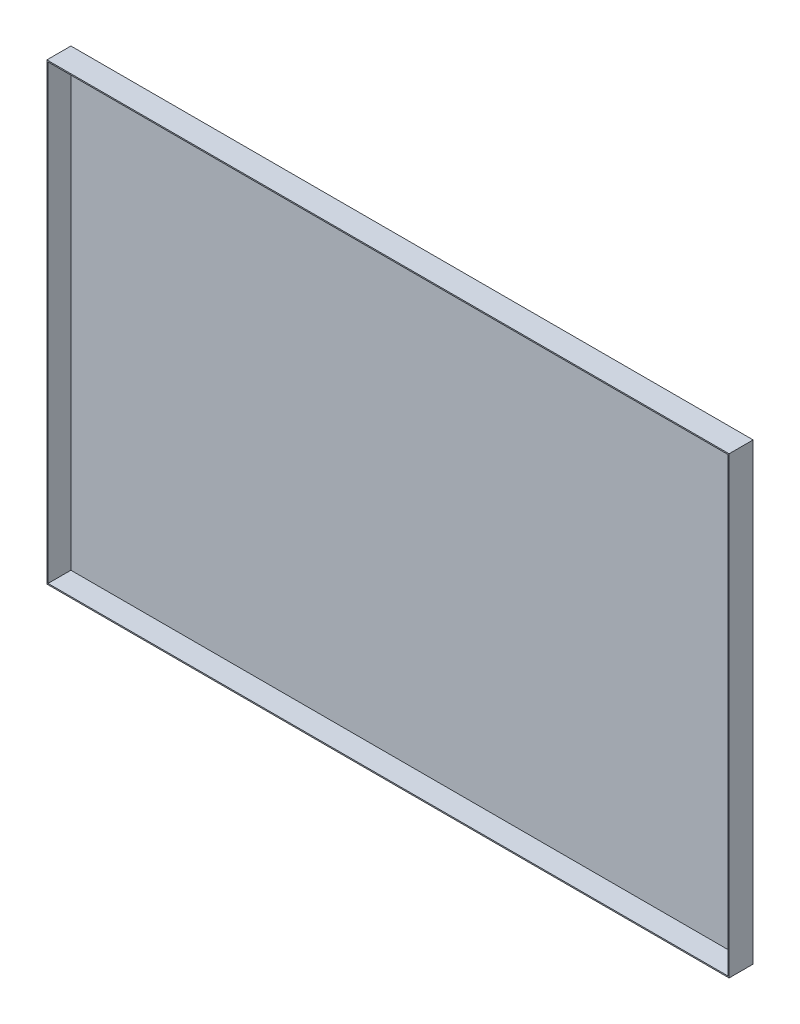
from build123d import *

# Parameters (mm, degrees)
SKETCH_1_W      = 568
SKETCH_1_H      = 378
EXTRUDE_1_DEPTH = 20
SHELL_1_T       = -1


with BuildPart() as part:
    # 草图1 → 凸台-拉伸1 (new body)
    with BuildSketch(Plane.XY):
        Rectangle(SKETCH_1_W, SKETCH_1_H)
    extrude(amount=EXTRUDE_1_DEPTH)

    # 抽壳1
    shell_1_openings = [part.faces().sort_by_distance(p)[0] for p in [
        (0, 0, 20),
    ]]
    offset(amount=SHELL_1_T, openings=shell_1_openings, kind=Kind.INTERSECTION)


solid = part.part
